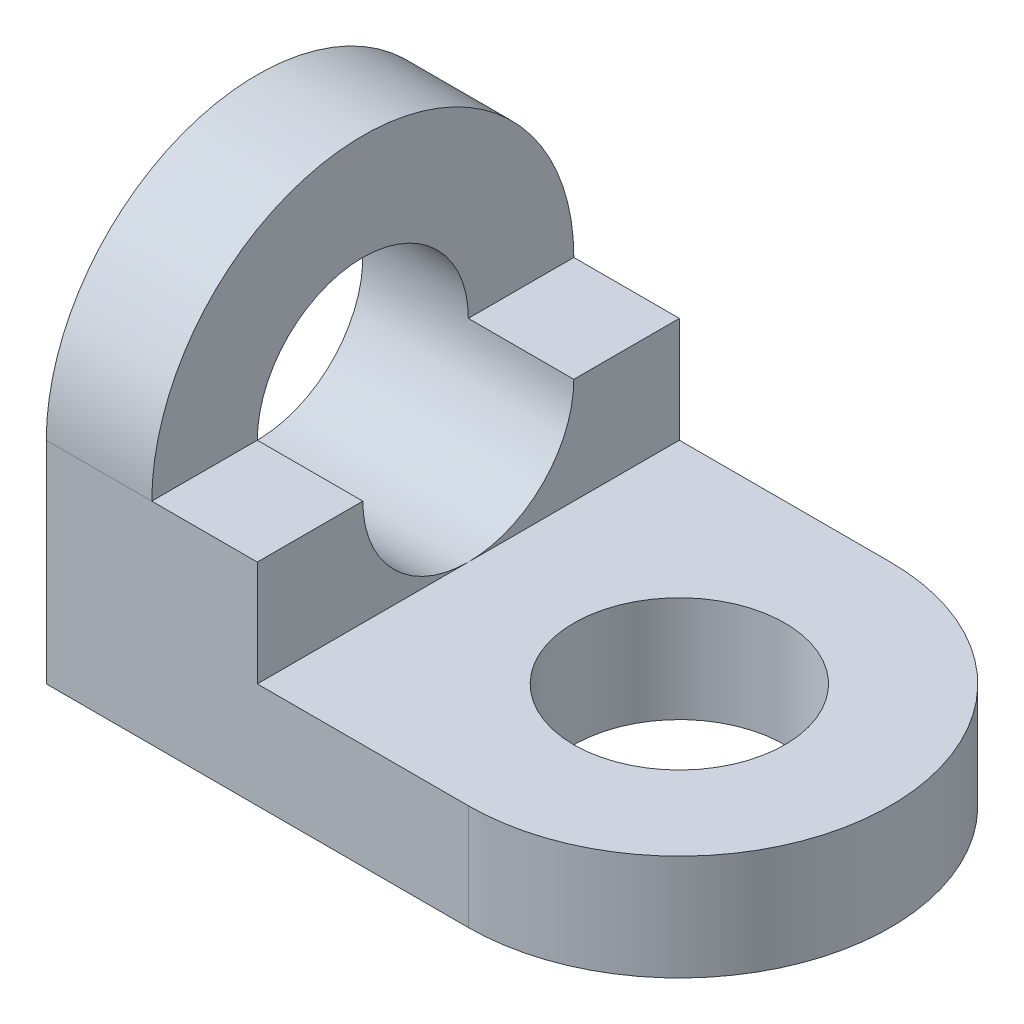
from build123d import *

# Parameters (mm, degrees)
SKETCH1_R           = 254
BOSS_EXTRUDE1_DEPTH = 254
SKETCH1_3_W         = 254
SKETCH1_3_H         = 1016
BOSS_EXTRUDE2_DEPTH = 508
SKETCH1_4_W         = 254
SKETCH1_4_H         = 1016
BOSS_EXTRUDE3_DEPTH = 1016
SKETCH2_R           = 254
CUT_EXTRUDE2_DEPTH  = 2095.537657814
CUT_EXTRUDE3_DEPTH  = 254


with BuildPart() as part:
    # Sketch1 → Boss-Extrude1 (new body)
    with BuildSketch(Plane(origin=(0, 0, 0), x_dir=(1, 0, 0), z_dir=(0, 1, 0))):
        with BuildLine():
            Line((508, 0), (1016, 0))
            ThreePointArc((1016, 0), (1524, 508), (1016, 1016))
            Line((1016, 1016), (508, 1016))
            Line((508, 1016), (508, 0))
        make_face()
        with Locations((1016, 508)):
            Circle(SKETCH1_R, mode=Mode.SUBTRACT)
    extrude(amount=BOSS_EXTRUDE1_DEPTH)

    # Sketch1_3 → Boss-Extrude2 (add)
    with BuildSketch(Plane(origin=(0, 0, 0), x_dir=(1, 0, 0), z_dir=(0, 1, 0))):
        with Locations((381, 508)):
            Rectangle(SKETCH1_3_W, SKETCH1_3_H)
    extrude(amount=BOSS_EXTRUDE2_DEPTH)

    # Sketch1_4 → Boss-Extrude3 (add)
    with BuildSketch(Plane(origin=(0, 0, 0), x_dir=(1, 0, 0), z_dir=(0, 1, 0))):
        with Locations((127, 508)):
            Rectangle(SKETCH1_4_W, SKETCH1_4_H)
    extrude(amount=BOSS_EXTRUDE3_DEPTH)

    # Sketch2 → Cut-Extrude2 (cut, through all)
    with BuildSketch(Plane.ZY):
        with Locations((-508, 508)):
            Circle(SKETCH2_R)
    extrude(amount=-CUT_EXTRUDE2_DEPTH, mode=Mode.SUBTRACT)

    # Sketch2_4 → Cut-Extrude3 (cut)
    with BuildSketch(Plane.ZY):
        with BuildLine():
            ThreePointArc((-508, 1016), (-148.789755157, 867.210244843), (0, 508))
            Line((0, 508), (0, 1016))
            Line((0, 1016), (-508, 1016))
        make_face()
        with BuildLine():
            ThreePointArc((-1016, 508), (-867.210244843, 867.210244843), (-508, 1016))
            Line((-508, 1016), (-1016, 1016))
            Line((-1016, 1016), (-1016, 508))
        make_face()
    extrude(amount=-CUT_EXTRUDE3_DEPTH, mode=Mode.SUBTRACT)


solid = part.part
